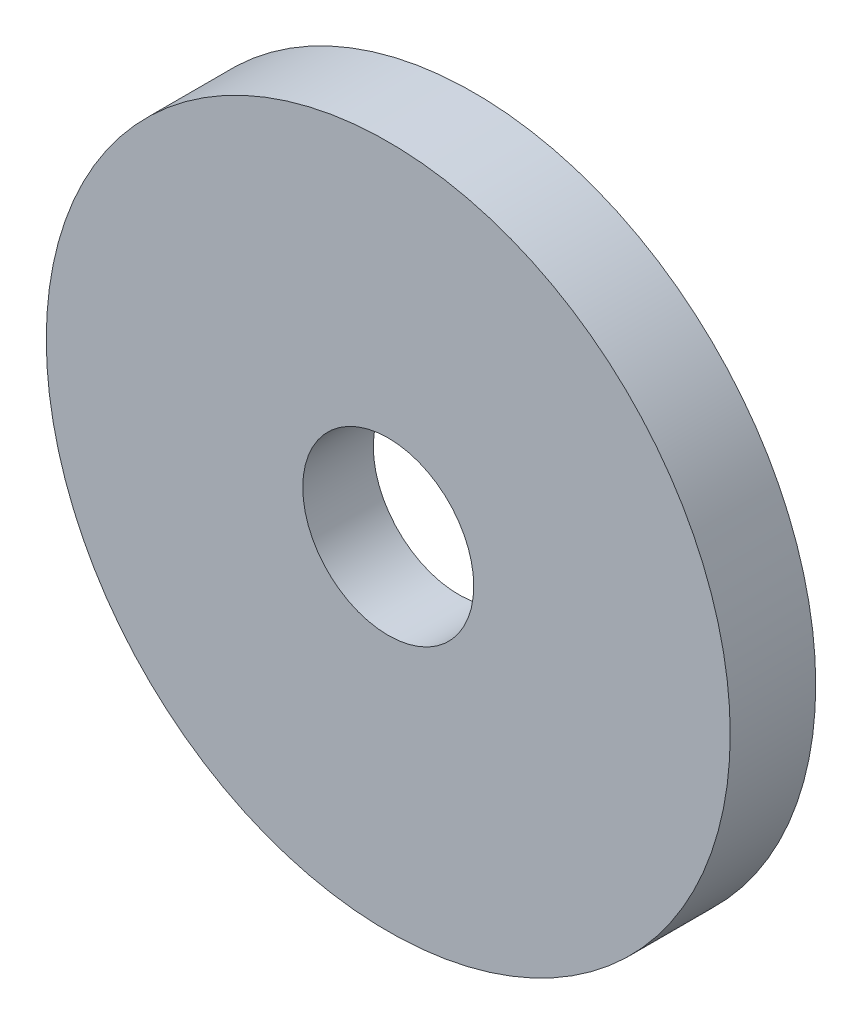
from build123d import *

# Parameters (mm, degrees)
CROQUIS1_R              = 1
CROQUIS1_R_2            = 0.25
SALIENTE_EXTRUIR1_DEPTH = 0.25


with BuildPart() as part:
    # Croquis1 → Saliente-Extruir1 (new body)
    with BuildSketch(Plane.XY):
        Circle(CROQUIS1_R)
        Circle(CROQUIS1_R_2, mode=Mode.SUBTRACT)
    extrude(amount=SALIENTE_EXTRUIR1_DEPTH)

    # Cortar-Extruir1 cone 1 section (through the dimple's axis) → Cortar-Extruir1 (revolve, cut)
    with BuildSketch(Plane.YZ):
        Polygon((0, 0), (0.75, 0), (0, 0.065616498), align=None)
    revolve(axis=Axis((0, 0, 0), (0, 0, 1)), mode=Mode.SUBTRACT)


solid = part.part
